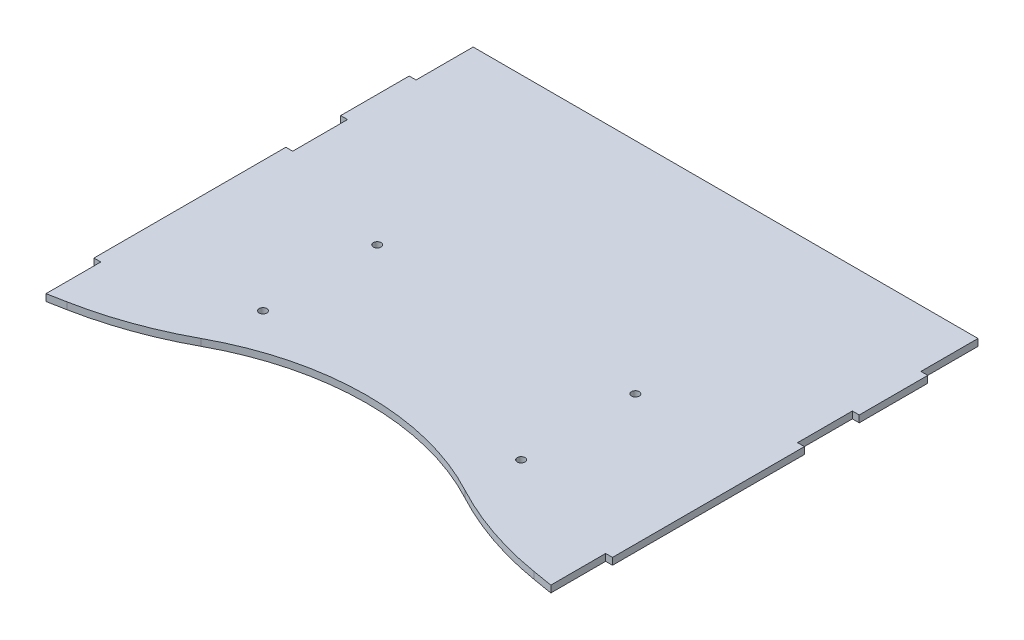
from build123d import *

# Parameters (mm, degrees)
CROQUIS1_R              = 1.7
SALIENTE_EXTRUIR1_DEPTH = 3


with BuildPart() as part:
    # Croquis1 → Saliente-Extruir1 (new body)
    with BuildSketch(Plane(origin=(0, 0, 0), x_dir=(1, 0, 0), z_dir=(0, 1, 0))):
        with BuildLine():
            Line((-99.377556398, 10.005876847), (-102.377556398, 10.005876847))
            Line((-102.377556398, 10.005876847), (-102.377556398, -73.994123153))
            Line((-102.377556398, -73.994123153), (-99.377556398, -73.994123153))
            Line((-99.377556398, -73.994123153), (-99.377556398, -97.994123153))
            Line((-99.377556398, -97.994123153), (-91.7405656, -96.529736825))
            ThreePointArc((-91.7405656, -96.529736825), (-69.468775837, -90.450126114), (-48.393725101, -81.024813273))
            ThreePointArc((-48.393725101, -81.024813273), (9.137426833, -66.335488141), (66.738359446, -80.748755569))
            ThreePointArc((66.738359446, -80.748755569), (89.168735578, -90.527731735), (112.890583803, -96.529736825))
            Line((112.890583803, -96.529736825), (121.622443602, -97.994123153))
            Line((121.622443602, -97.994123153), (121.622443602, -73.994123153))
            Line((121.622443602, -73.994123153), (124.622443602, -73.994123153))
            Line((124.622443602, -73.994123153), (124.622443602, 10.005876847))
            Line((124.622443602, 10.005876847), (121.622443602, 10.005876847))
            Line((121.622443602, 10.005876847), (121.622443602, 34.005876847))
            Line((121.622443602, 34.005876847), (124.622443602, 34.005876847))
            Line((124.622443602, 34.005876847), (124.622443602, 64.005876847))
            Line((124.622443602, 64.005876847), (121.622443602, 64.005876847))
            Line((121.622443602, 64.005876847), (121.622443602, 89.005112069))
            Line((121.622443602, 89.005112069), (-99.377556398, 89.005839795))
            Line((-99.377556398, 89.005839795), (-99.377556398, 64.005876847))
            Line((-99.377556398, 64.005876847), (-102.377556398, 64.005876847))
            Line((-102.377556398, 64.005876847), (-102.377556398, 34.005876847))
            Line((-102.377556398, 34.005876847), (-99.377556398, 34.005876847))
            Line((-99.377556398, 34.005876847), (-99.377556398, 10.005876847))
        make_face()
        with Locations((-45.378037158, -56.994306397)):
            Circle(CROQUIS1_R, mode=Mode.SUBTRACT)
        with Locations((-45.377872514, -6.994306397)):
            Circle(CROQUIS1_R, mode=Mode.SUBTRACT)
        with Locations((67.622759718, -6.994306397)):
            Circle(CROQUIS1_R, mode=Mode.SUBTRACT)
        with Locations((67.622924362, -56.994306397)):
            Circle(CROQUIS1_R, mode=Mode.SUBTRACT)
    extrude(amount=SALIENTE_EXTRUIR1_DEPTH)


solid = part.part
